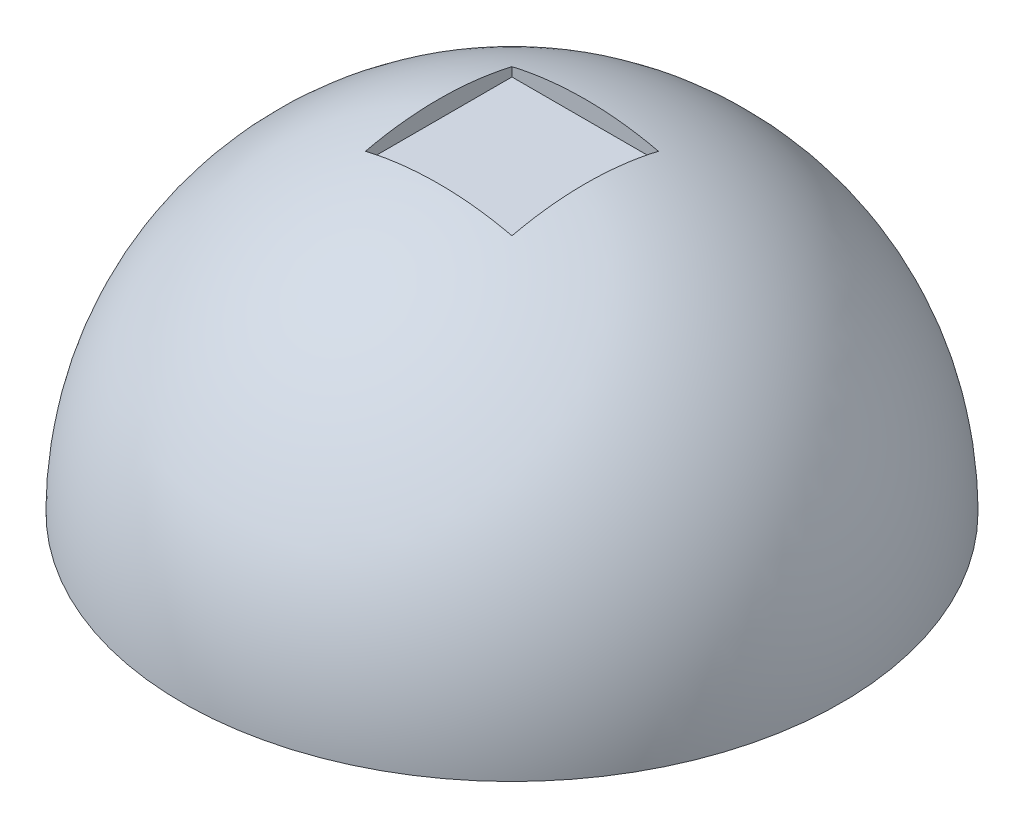
from build123d import *

# Parameters (mm, degrees)
SKETCH2_W          = 101.6
SKETCH2_H          = 101.6
CUT_EXTRUDE1_DEPTH = 17.78


with BuildPart() as part:
    # Sketch1 → Revolve1 (revolve)
    with BuildSketch(Plane.XY):
        with BuildLine():
            Line((0, 0), (228.6, 0))
            ThreePointArc((228.6, 0), (161.644610179, 161.644610179), (0, 228.6))
            Line((0, 228.6), (0, 0))
        make_face()
    revolve(axis=Axis((0, 0, 0), (0, 1, 0)))

    # Sketch2 → Cut-Extrude1 (cut)
    with BuildSketch(Plane(origin=(0, 228.6, 0), x_dir=(1, 0, 0), z_dir=(0, 1, 0))):
        Rectangle(SKETCH2_W, SKETCH2_H)
    extrude(amount=-CUT_EXTRUDE1_DEPTH, mode=Mode.SUBTRACT)


solid = part.part
